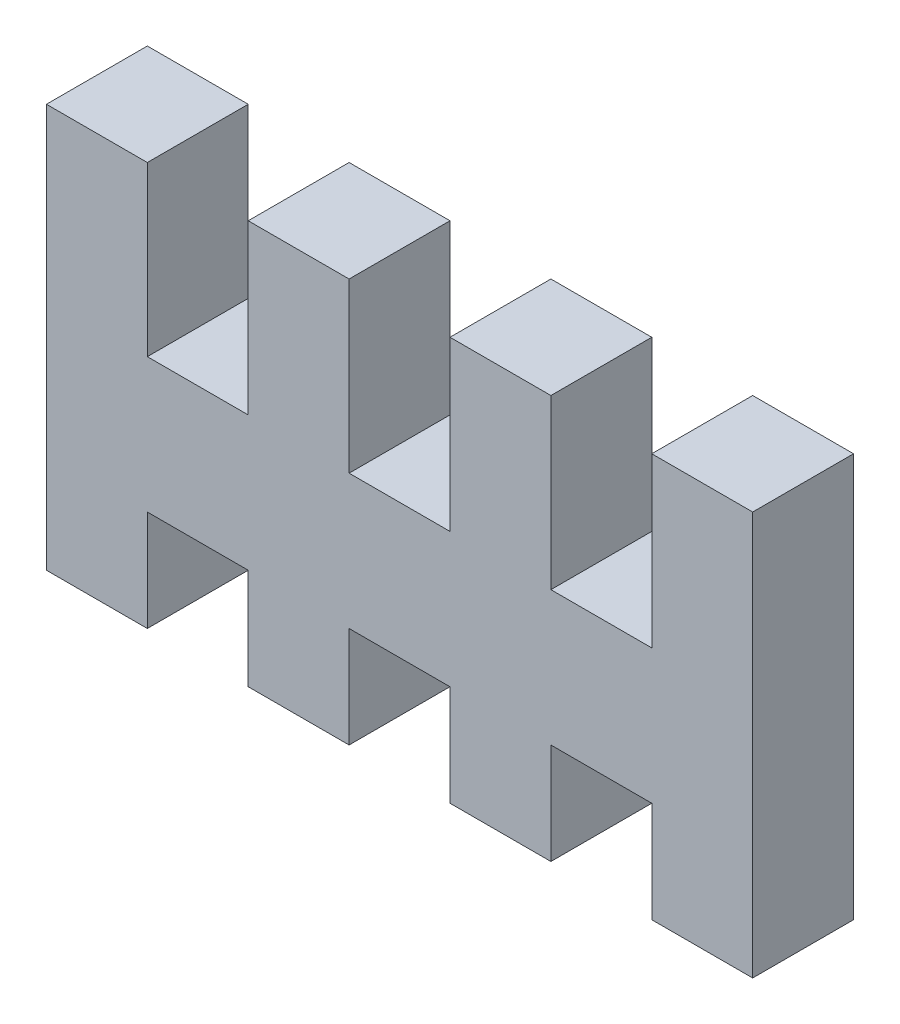
from build123d import *

# Parameters (mm, degrees)
ESQUISSE1_W        = 21
ESQUISSE1_H        = 4
ESQUISSE1_W_2      = 3
ESQUISSE1_H_2      = 3
ESQUISSE1_H_3      = 5
BOSS_EXTRU_1_DEPTH = 3


with BuildPart() as part:
    # Esquisse1 → Boss.-Extru.1 (new body)
    with BuildSketch(Plane.XY):
        with Locations((10.5, 2)):
            Rectangle(ESQUISSE1_W, ESQUISSE1_H)
        with Locations((1.5, -1.5)):
            Rectangle(ESQUISSE1_W_2, ESQUISSE1_H_2)
        with Locations((7.5, -1.5)):
            Rectangle(ESQUISSE1_W_2, ESQUISSE1_H_2)
        with Locations((13.5, -1.5)):
            Rectangle(ESQUISSE1_W_2, ESQUISSE1_H_2)
        with Locations((19.5, -1.5)):
            Rectangle(ESQUISSE1_W_2, ESQUISSE1_H_2)
        with Locations((19.5, 6.5)):
            Rectangle(ESQUISSE1_W_2, ESQUISSE1_H_3)
        with Locations((13.5, 6.5)):
            Rectangle(ESQUISSE1_W_2, ESQUISSE1_H_3)
        with Locations((1.5, 6.5)):
            Rectangle(ESQUISSE1_W_2, ESQUISSE1_H_3)
        with Locations((7.5, 6.5)):
            Rectangle(ESQUISSE1_W_2, ESQUISSE1_H_3)
    extrude(amount=BOSS_EXTRU_1_DEPTH)


solid = part.part
